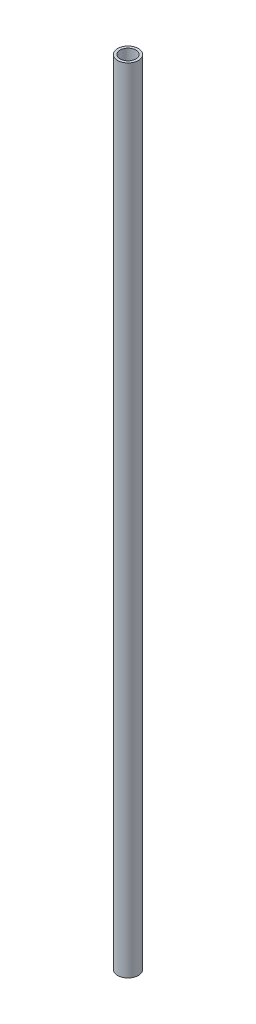
from build123d import *

# Parameters (mm, degrees)
SKETCH1_R           = 12.7
SKETCH1_R_2         = 9.525
BOSS_EXTRUDE1_DEPTH = 484.1875


with BuildPart() as part:
    # Sketch1 → Boss-Extrude1 (new body, symmetric)
    with BuildSketch(Plane(origin=(0, 0, 0), x_dir=(1, 0, 0), z_dir=(0, 1, 0))):
        Circle(SKETCH1_R)
        Circle(SKETCH1_R_2, mode=Mode.SUBTRACT)
    extrude(amount=BOSS_EXTRUDE1_DEPTH, both=True)


solid = part.part
